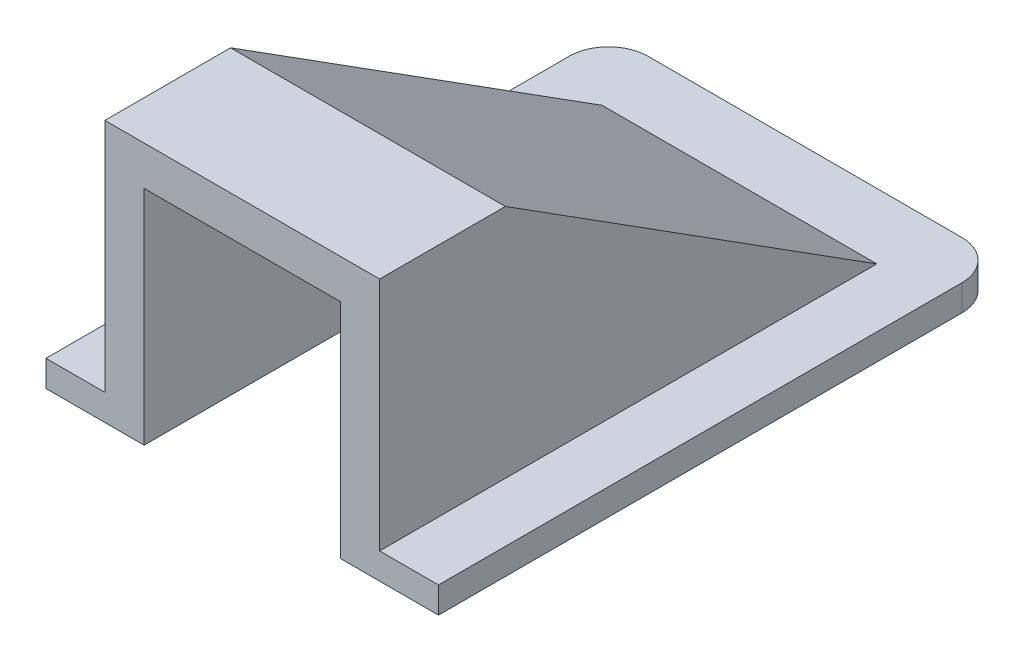
from build123d import *

# Parameters (mm, degrees)
CROQUIS2_W              = 43
CROQUIS2_H              = 30
SALIENTE_EXTRUIR1_DEPTH = 30
CROQUIS3_W              = 42.529407755
CROQUIS3_H              = 25.558495791
CORTAR_EXTRUIR1_DEPTH   = 30
CORTAR_EXTRUIR2_START   = -7.5
CORTAR_EXTRUIR2_DEPTH   = 15
CORTAR_EXTRUIR4_DEPTH   = 4.5
CORTAR_EXTRUIR5_DEPTH   = 4.5
REDONDEO1_R             = 3
CROQUIS8_W              = 15
CROQUIS8_H              = 32.397186909
CORTAR_EXTRUIR6_DEPTH   = 4.5
CROQUIS9_W              = 120.283196461
CROQUIS9_H              = 78.810135234
CORTAR_EXTRUIR7_DEPTH   = 22.5


with BuildPart() as part:
    # Croquis2 → Saliente-Extruir1 (new body)
    with BuildSketch(Plane(origin=(0, 0, 0), x_dir=(0, 0, -1), z_dir=(1, 0, 0))):
        with Locations((-19.783269962, -13.522813688)):
            Rectangle(CROQUIS2_W, CROQUIS2_H)
    extrude(amount=SALIENTE_EXTRUIR1_DEPTH)

    # Croquis3 → Cortar-Extruir1 (cut)
    with BuildSketch(Plane(origin=(30, 0, 0), x_dir=(0, 0, -1), z_dir=(1, 0, 0))):
        with Locations((-17.018566085, -31.302061584)):
            Rectangle(CROQUIS3_W, CROQUIS3_H)
        Polygon((-31.675073764, 1.477186312), (-3.283269962, -16.522813688), (1.716730038, -16.522813688), (1.716730038, 1.477186312), align=None)
    extrude(amount=-CORTAR_EXTRUIR1_DEPTH, mode=Mode.SUBTRACT)

    # Croquis4 → Cortar-Extruir2 (cut)
    with BuildSketch(Plane(origin=(30, 0, 0), x_dir=(0, 0, -1), z_dir=(1, 0, 0)).offset(CORTAR_EXTRUIR2_START)):
        Polygon((-41.283269962, -1.522813688), (-32.545919554, -1.522813688), (-8.886083053, -16.522813688), (-41.283269962, -16.522813688), align=None)
    extrude(amount=-CORTAR_EXTRUIR2_DEPTH, mode=Mode.SUBTRACT)

    # Croquis5 → Cortar-Extruir4 (cut)
    with BuildSketch(Plane(origin=(30, 0, 0), x_dir=(0, 0, -1), z_dir=(1, 0, 0))):
        Polygon((-3.283269962, -16.522813688), (-41.283269962, -16.522813688), (-41.283269962, 1.477186312), (-31.675073764, 1.477186312), align=None)
    extrude(amount=-CORTAR_EXTRUIR4_DEPTH, mode=Mode.SUBTRACT)

    # Croquis6 → Cortar-Extruir5 (cut)
    with BuildSketch(Plane.ZY):
        Polygon((3.283269962, -16.522813688), (41.283269962, -16.522813688), (41.283269962, 1.477186312), (31.675073764, 1.477186312), align=None)
    extrude(amount=-CORTAR_EXTRUIR5_DEPTH, mode=Mode.SUBTRACT)

    # Redondeo1
    redondeo1_edges = [part.edges().sort_by_distance(p)[0] for p in [
        (0, -17.522813688, -1.716730038),
        (30, -17.522813688, -1.716730038),
    ]]
    fillet(redondeo1_edges, radius=REDONDEO1_R)

    # Croquis8 → Cortar-Extruir6 (cut)
    with BuildSketch(Plane(origin=(0, -16.522813688, 0), x_dir=(1, 0, 0), z_dir=(0, 1, 0))):
        with Locations((15, -25.084676508)):
            Rectangle(CROQUIS8_W, CROQUIS8_H)
    extrude(amount=-CORTAR_EXTRUIR6_DEPTH, mode=Mode.SUBTRACT)

    # Croquis9 → Cortar-Extruir7 (cut)
    with BuildSketch(Plane.XZ.offset(18.522813688)):
        with Locations((17.6156444, 62.089659259)):
            Rectangle(CROQUIS9_W, CROQUIS9_H)
    extrude(amount=CORTAR_EXTRUIR7_DEPTH, mode=Mode.SUBTRACT)


solid = part.part
